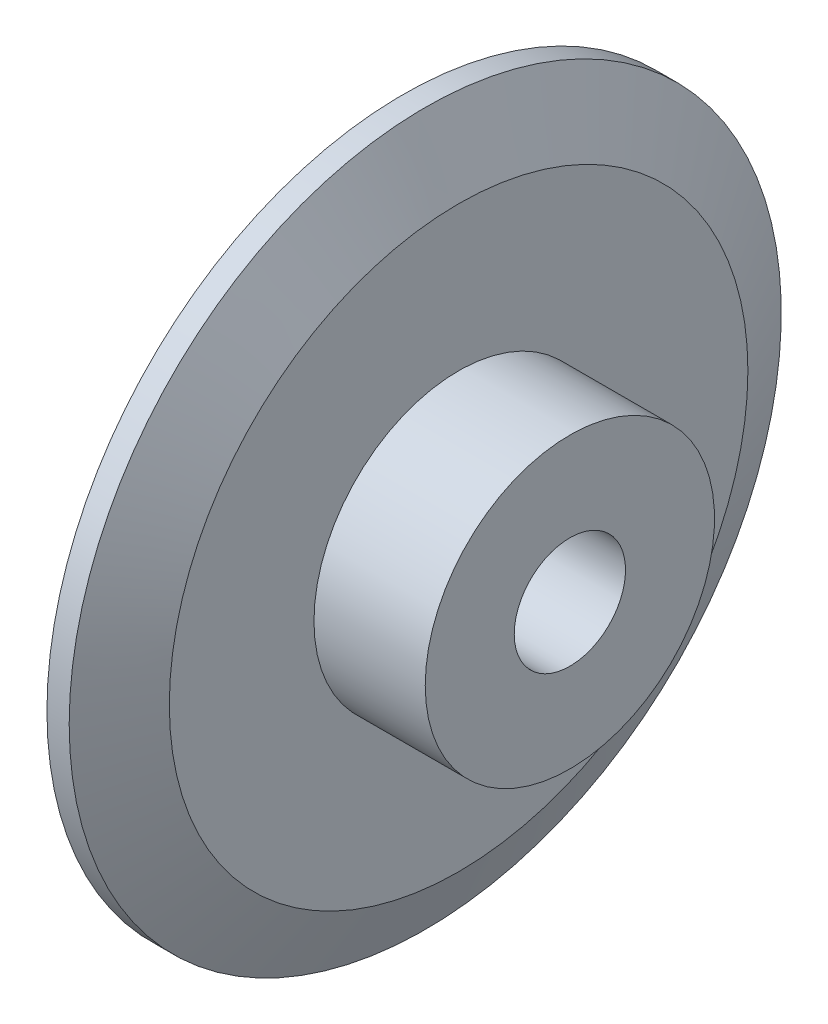
from build123d import *


with BuildPart() as part:
    # Esquisse1 → Révolution1 (revolve)
    with BuildSketch(Plane.XY):
        Polygon((-2, 2.5), (7, 2.5), (7, 6.5), (2, 6.5), (2, 13), (0.5, 16), (-0.5, 16), (-2, 13), align=None)
    revolve(axis=Axis((-14.530010417, 0, 0), (1, 0, 0)))


solid = part.part
